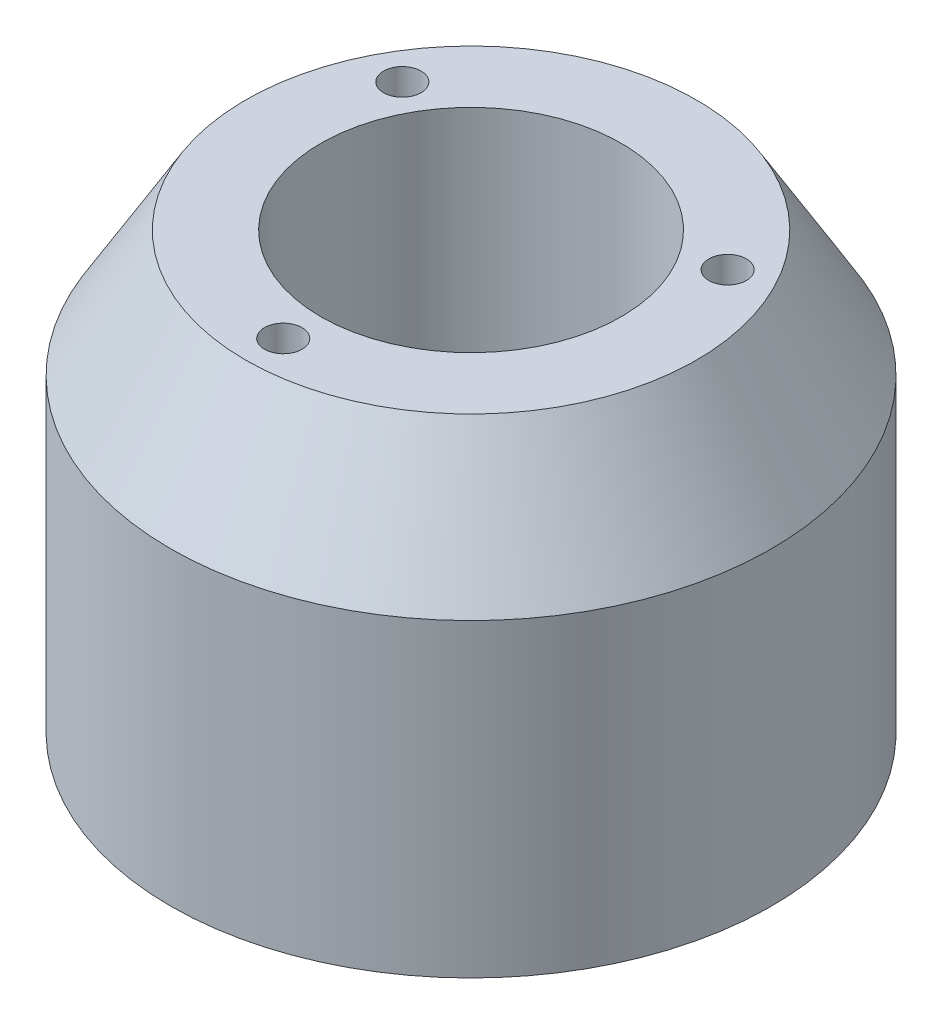
from build123d import *

# Parameters (mm, degrees)
ESQUISSE2_R             = 20
ENL_V_MAT_EXTRU_1_DEPTH = 58.940669043
TROU_TARAUD_M61_D       = 5
TROU_TARAUD_M61_DEPTH   = 17
TROU_TARAUD_M61_TIP     = 1.502151548
TROU_TARAUD_M62_D       = 5
TROU_TARAUD_M62_DEPTH   = 28
TROU_TARAUD_M62_TIP     = 1.502151548


with BuildPart() as part:
    # Esquisse1 → Révolution1 (revolve)
    with BuildSketch(Plane.XY, mode=Mode.PRIVATE) as r_volution1_sk:
        Polygon((0, 0), (40, 0), (40, 41.2), (30, 57.940669043), (0, 57.940669043), align=None)
    revolve(r_volution1_sk.sketch.rotate(Axis((0, 57.940669043, 0), (0, -1, 0)), 90), axis=Axis((0, 57.940669043, 0), (0, -1, 0)))  # turned: the seam where the file's is

    # Esquisse2 → Enlèv. mat.-Extru.1 (cut, through all)
    with BuildSketch(Plane(origin=(0, 57.940669043, 0), x_dir=(1, 0, 0), z_dir=(0, 1, 0))):
        with Locations(Location((0, 0, 0), (0, 0, 270))):  # turned: the seam where the file's is
            Circle(ESQUISSE2_R)
    extrude(amount=-ENL_V_MAT_EXTRU_1_DEPTH, mode=Mode.SUBTRACT)

    # Trou taraudé M61
    with Locations(Plane(origin=(-21.650635095, 57.940669043, -12.5), x_dir=(0, 0, 1), z_dir=(0, 1, 0))):
        with Locations((0, 0), (0, 43.30127019), (37.5, 21.650635095)):
            Hole(TROU_TARAUD_M61_D / 2, depth=TROU_TARAUD_M61_DEPTH)
            with Locations((0, 0, -(TROU_TARAUD_M61_DEPTH + TROU_TARAUD_M61_TIP / 2))):  # 118° drill point
                Cone(0, TROU_TARAUD_M61_D / 2, TROU_TARAUD_M61_TIP, mode=Mode.SUBTRACT)

    # Trou taraudé M62
    with Locations(Plane(origin=(0, 0, 30), x_dir=(0, 0, -1), z_dir=(0, -1, 0))):
        with Locations((0, 0), (30, 30), (60, 0), (30, -30)):
            Hole(TROU_TARAUD_M62_D / 2, depth=TROU_TARAUD_M62_DEPTH)
            with Locations((0, 0, -(TROU_TARAUD_M62_DEPTH + TROU_TARAUD_M62_TIP / 2))):  # 118° drill point
                Cone(0, TROU_TARAUD_M62_D / 2, TROU_TARAUD_M62_TIP, mode=Mode.SUBTRACT)


solid = part.part
